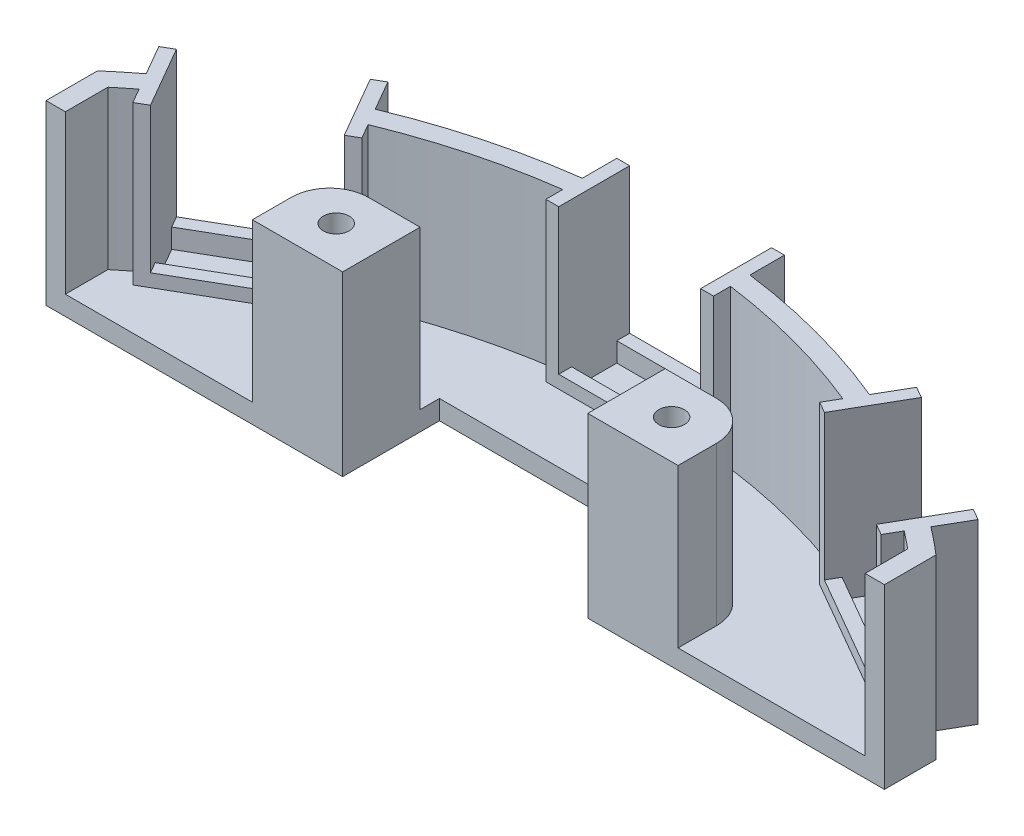
from build123d import *

# Parameters (mm, degrees)
EXTRUDE_1842_DEPTH     = 3
SKETCH_5_W             = 14
SKETCH_5_H             = 12
EXTRUDE_4250_DEPTH     = 24.5
SKETCH_9_W             = 22
SKETCH_9_H             = 11
EXTRUDE_5165_DEPTH     = 2
SKETCH_11_W            = 22
SKETCH_11_H            = 7
CUT_EXTRUDE_6076_DEPTH = 3
SKETCH_6_R             = 2
CUT_EXTRUDE_6516_DEPTH = 127.101149876
FILLET_2_R             = 6


with BuildPart() as part:
    # 草图1 → Extrude 1842 (new body)
    with BuildSketch(Plane(origin=(0, 0, 0), x_dir=(1, 0, 0), z_dir=(0, 1, 0))):
        with BuildLine():
            Line((-65, 75.993420768), (-65, 68))
            Line((-65, 68), (-19, 68))
            Line((-19, 68), (-19, 83))
            Line((-19, 83), (19, 83))
            Line((19, 83), (19, 68))
            Line((19, 68), (65, 68))
            Line((65, 68), (65, 75.993420768))
            ThreePointArc((65, 75.993420768), (62.939630568, 77.708448086), (60.834029942, 79.367630688))
            Line((60.834029942, 79.367630688), (63.508330249, 83.999654695))
            Line((63.508330249, 83.999654695), (40.991669751, 96.999654695))
            Line((40.991669751, 96.999654695), (38.317369443, 92.367630688))
            ThreePointArc((38.317369443, 92.367630688), (25.88190451, 96.592582629), (13, 99.151399385))
            Line((13, 99.151399385), (13, 104.5))
            Line((13, 104.5), (-13, 104.5))
            Line((-13, 104.5), (-13, 99.151399385))
            ThreePointArc((-13, 99.151399385), (-25.88190451, 96.592582629), (-38.317369443, 92.367630688))
            Line((-38.317369443, 92.367630688), (-40.991669751, 96.999654695))
            Line((-40.991669751, 96.999654695), (-63.508330249, 83.999654695))
            Line((-63.508330249, 83.999654695), (-60.834029942, 79.367630688))
            ThreePointArc((-60.834029942, 79.367630688), (-62.939630568, 77.708448086), (-65, 75.993420768))
        make_face()
    extrude(amount=-EXTRUDE_1842_DEPTH)

    # 草图5 → Extrude 4250 (add)
    with BuildSketch(Plane(origin=(0, 0, 0), x_dir=(1, 0, 0), z_dir=(0, 1, 0))):
        with BuildLine():
            Line((-11, 104.5), (-13, 104.5))
            Line((-13, 104.5), (-13, 99.151399385))
            ThreePointArc((-13, 99.151399385), (-25.88190451, 96.592582629), (-38.317369443, 92.367630688))
            Line((-38.317369443, 92.367630688), (-40.991669751, 96.999654695))
            Line((-40.991669751, 96.999654695), (-42.723720558, 95.999654695))
            Line((-42.723720558, 95.999654695), (-37.223720558, 86.473375254))
            Line((-37.223720558, 86.473375254), (-35.491669751, 87.473375254))
            Line((-35.491669751, 87.473375254), (-36.804129114, 89.746621553))
            ThreePointArc((-36.804129114, 89.746621553), (-25.105447375, 93.69480515), (-13, 96.124918726))
            Line((-13, 96.124918726), (-13, 93.5))
            Line((-13, 93.5), (-11, 93.5))
            Line((-11, 93.5), (-11, 104.5))
        make_face()
        with BuildLine():
            Line((13, 104.5), (11, 104.5))
            Line((11, 104.5), (11, 93.5))
            Line((11, 93.5), (13, 93.5))
            Line((13, 93.5), (13, 96.124918726))
            ThreePointArc((13, 96.124918726), (25.105447375, 93.69480515), (36.804129114, 89.746621553))
            Line((36.804129114, 89.746621553), (35.491669751, 87.473375254))
            Line((35.491669751, 87.473375254), (37.223720558, 86.473375254))
            Line((37.223720558, 86.473375254), (42.723720558, 95.999654695))
            Line((42.723720558, 95.999654695), (40.991669751, 96.999654695))
            Line((40.991669751, 96.999654695), (38.317369443, 92.367630688))
            ThreePointArc((38.317369443, 92.367630688), (25.88190451, 96.592582629), (13, 99.151399385))
            Line((13, 99.151399385), (13, 104.5))
        make_face()
        with BuildLine():
            Line((-61.776279442, 84.999654695), (-63.508330249, 83.999654695))
            Line((-63.508330249, 83.999654695), (-60.834029942, 79.367630688))
            ThreePointArc((-60.834029942, 79.367630688), (-62.939630568, 77.708448086), (-65, 75.993420768))
            Line((-65, 75.993420768), (-65, 68))
            Line((-65, 68), (-62, 68))
            Line((-62, 68), (-62, 74.598927606))
            ThreePointArc((-62, 74.598927606), (-60.669899006, 75.684630901), (-59.320789612, 76.746621553))
            Line((-59.320789612, 76.746621553), (-58.008330249, 74.473375254))
            Line((-58.008330249, 74.473375254), (-56.276279442, 75.473375254))
            Line((-56.276279442, 75.473375254), (-61.776279442, 84.999654695))
        make_face()
        with BuildLine():
            Line((58.008330249, 74.473375254), (59.320789612, 76.746621553))
            ThreePointArc((59.320789612, 76.746621553), (60.669899006, 75.684630901), (62, 74.598927606))
            Line((62, 74.598927606), (62, 68))
            Line((62, 68), (65, 68))
            Line((65, 68), (65, 75.993420768))
            ThreePointArc((65, 75.993420768), (62.939630568, 77.708448086), (60.834029942, 79.367630688))
            Line((60.834029942, 79.367630688), (63.508330249, 83.999654695))
            Line((63.508330249, 83.999654695), (61.776279442, 84.999654695))
            Line((61.776279442, 84.999654695), (56.276279442, 75.473375254))
            Line((56.276279442, 75.473375254), (58.008330249, 74.473375254))
        make_face()
        with Locations((-26, 74)):
            Rectangle(SKETCH_5_W, SKETCH_5_H)
        with Locations((26, 74)):
            Rectangle(SKETCH_5_W, SKETCH_5_H)
    extrude(amount=EXTRUDE_4250_DEPTH)

    # 草图9 → Extrude 5165 (add)
    with BuildSketch(Plane(origin=(0, 0, 0), x_dir=(1, 0, 0), z_dir=(0, 1, 0))):
        Polygon((-56.276279442, 75.473375254), (-37.223720558, 86.473375254), (-42.723720558, 95.999654695), (-61.776279442, 84.999654695), align=None)
        with Locations((0, 99)):
            Rectangle(SKETCH_9_W, SKETCH_9_H)
        Polygon((37.223720558, 86.473375254), (56.276279442, 75.473375254), (61.776279442, 84.999654695), (42.723720558, 95.999654695), align=None)
    extrude(amount=EXTRUDE_5165_DEPTH)

    # 草图11 → Cut-Extrude 6076 (cut)
    with BuildSketch(Plane(origin=(0, 2, 0), x_dir=(1, 0, 0), z_dir=(0, 1, 0))):
        Polygon((-60.776279442, 83.267603888), (-41.723720558, 94.267603888), (-38.223720558, 88.205426061), (-57.276279442, 77.205426061), align=None)
        with Locations((0, 99)):
            Rectangle(SKETCH_11_W, SKETCH_11_H)
        Polygon((41.723720558, 94.267603888), (60.776279442, 83.267603888), (57.276279442, 77.205426061), (38.223720558, 88.205426061), align=None)
    extrude(amount=-CUT_EXTRUDE_6076_DEPTH, mode=Mode.SUBTRACT)

    # 草图6 → Cut-Extrude 6516 (cut, through all)
    with BuildSketch(Plane.XZ.offset(3)):
        with Locations(Location((-26, -74, 0), (0, 0, 270))):
            Circle(SKETCH_6_R)
        with Locations(Location((26, -74, 0), (0, 0, 270))):
            Circle(SKETCH_6_R)
    extrude(amount=-CUT_EXTRUDE_6516_DEPTH, mode=Mode.SUBTRACT)

    # 圆角2
    fillet_2_edges = [part.edges().sort_by_distance(p)[0] for p in [
        (-33, 12.25, -80),
        (33, 12.25, -80),
    ]]
    fillet(fillet_2_edges, radius=FILLET_2_R)


solid = part.part
